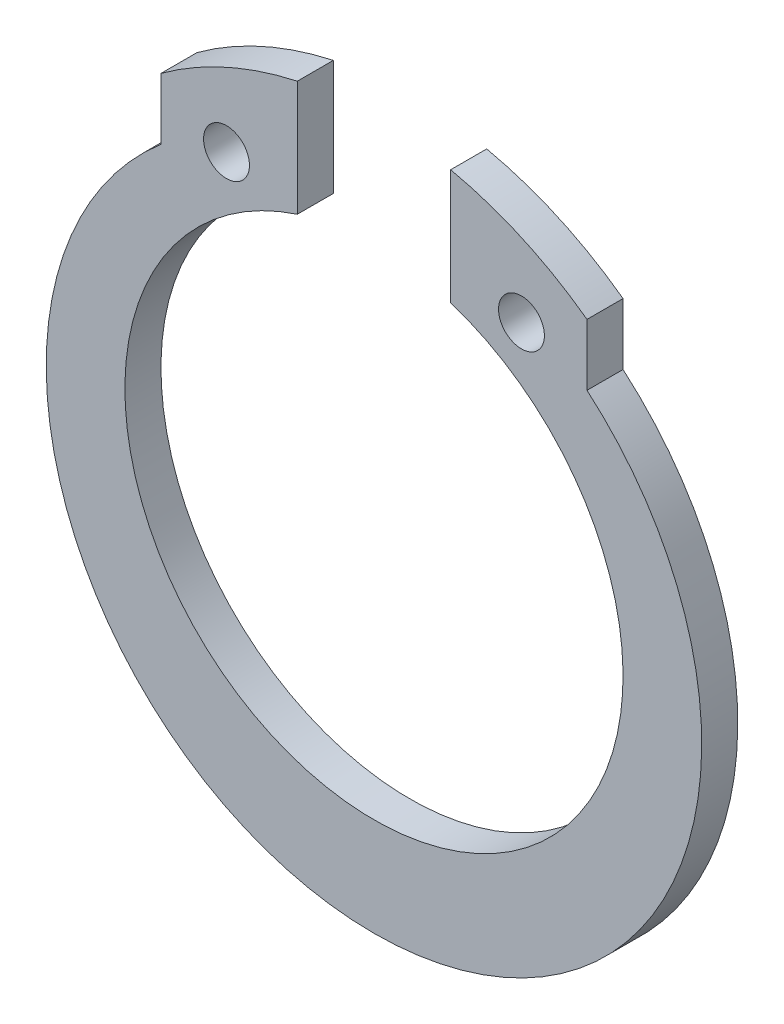
from build123d import *

# Parameters (mm, degrees)
BOSS_EXTRUDE1_DEPTH            = 0.55
SKETCH2_R                      = 3.8
CUT_EXTRUDE1_DEPTH             = 1.55
CUT_EXTRUDE2_DEPTH             = 1.55
F_0_7_0_7_DIAMETER_HOLE1_D     = 0.7
F_0_7_0_7_DIAMETER_HOLE1_DEPTH = 0.55


with BuildPart() as part:
    # Sketch1 → Boss-Extrude1 (new body)
    with BuildSketch(Plane.XY):
        with BuildLine():
            Line((-3.25, 4.737059837), (-3.25, 3.799671038))
            ThreePointArc((-3.25, 3.799671038), (0, -5), (3.25, 3.799671038))
            Line((3.25, 3.799671038), (3.25, 4.737059837))
            ThreePointArc((3.25, 4.737059837), (0, 5.8), (-3.25, 4.737059837))
        make_face()
    extrude(amount=-BOSS_EXTRUDE1_DEPTH)

    # Sketch2 → Cut-Extrude1 (cut, through all)
    with BuildSketch(Plane.XY):
        with Locations((0, 0.3)):
            Circle(SKETCH2_R)
    extrude(amount=-CUT_EXTRUDE1_DEPTH, mode=Mode.SUBTRACT)

    # Sketch3 → Cut-Extrude2 (cut, through all)
    with BuildSketch(Plane.XY):
        with BuildLine():
            Line((-1.17, 5.67411388), (-1.17, 3.915397627))
            ThreePointArc((-1.17, 3.915397627), (0, 4.1), (1.17, 3.915397627))
            Line((1.17, 3.915397627), (1.17, 5.67411388))
            ThreePointArc((1.17, 5.67411388), (0, 5.8), (-1.17, 5.67411388))
        make_face()
    extrude(amount=-CUT_EXTRUDE2_DEPTH, mode=Mode.SUBTRACT)

    # Ø0.7 (0.7) Diameter Hole1
    with Locations(Plane.XY):
        with Locations((-2.25, 4.197114317), (2.25, 4.197114317)):
            Hole(F_0_7_0_7_DIAMETER_HOLE1_D / 2, depth=F_0_7_0_7_DIAMETER_HOLE1_DEPTH)


solid = part.part
